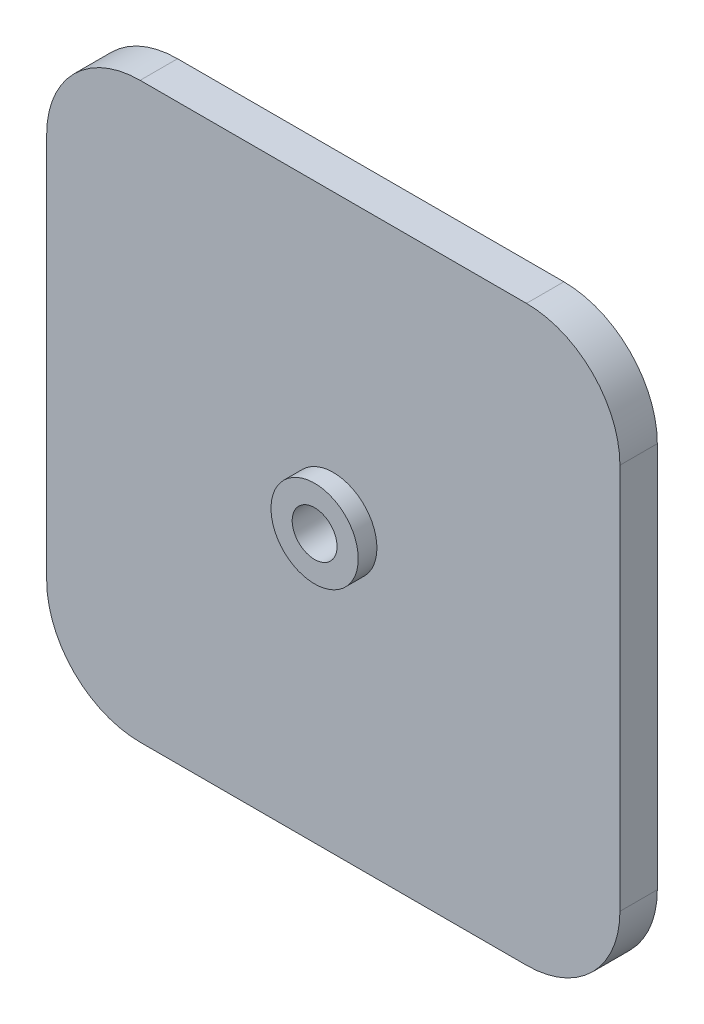
from build123d import *

# Parameters (mm, degrees)
BOSS_EXTRUDE1_DEPTH            = 3
SKETCH2_R                      = 3.5
BOSS_EXTRUDE2_DEPTH            = 1.5
M3_CLEARANCE_HOLE1_D           = 3.6
M3_CLEARANCE_HOLE1_ON_FACE_2_D = 3.6


with BuildPart() as part:
    # Sketch1 → Boss-Extrude1 (new body)
    with BuildSketch(Plane.XY):
        with BuildLine():
            Line((-15.5, 23), (15.5, 23))
            ThreePointArc((15.5, 23), (20.803300859, 20.803300859), (23, 15.5))
            Line((23, 15.5), (23, -15.5))
            ThreePointArc((23, -15.5), (20.803300859, -20.803300859), (15.5, -23))
            Line((15.5, -23), (-15.5, -23))
            ThreePointArc((-15.5, -23), (-20.803300859, -20.803300859), (-23, -15.5))
            Line((-23, -15.5), (-23, 15.5))
            ThreePointArc((-23, 15.5), (-20.803300859, 20.803300859), (-15.5, 23))
        make_face()
    extrude(amount=BOSS_EXTRUDE1_DEPTH)

    # Sketch2 → Boss-Extrude2 (add)
    with BuildSketch(Plane.XY.offset(3)):
        Circle(SKETCH2_R)
    extrude(amount=BOSS_EXTRUDE2_DEPTH)

    # M3 Clearance Hole1 (through all)
    with Locations(Plane(origin=(0, 0, 0), x_dir=(-1, 0, 0), z_dir=(0, 0, -1))):
        with Locations((0, 0)):
            Hole(M3_CLEARANCE_HOLE1_D / 2)

    # M3 Clearance Hole1 on face 2 (through all)
    with Locations(Plane.XY.offset(4.5)):
        with Locations((0, 0)):
            Hole(M3_CLEARANCE_HOLE1_ON_FACE_2_D / 2)


solid = part.part
